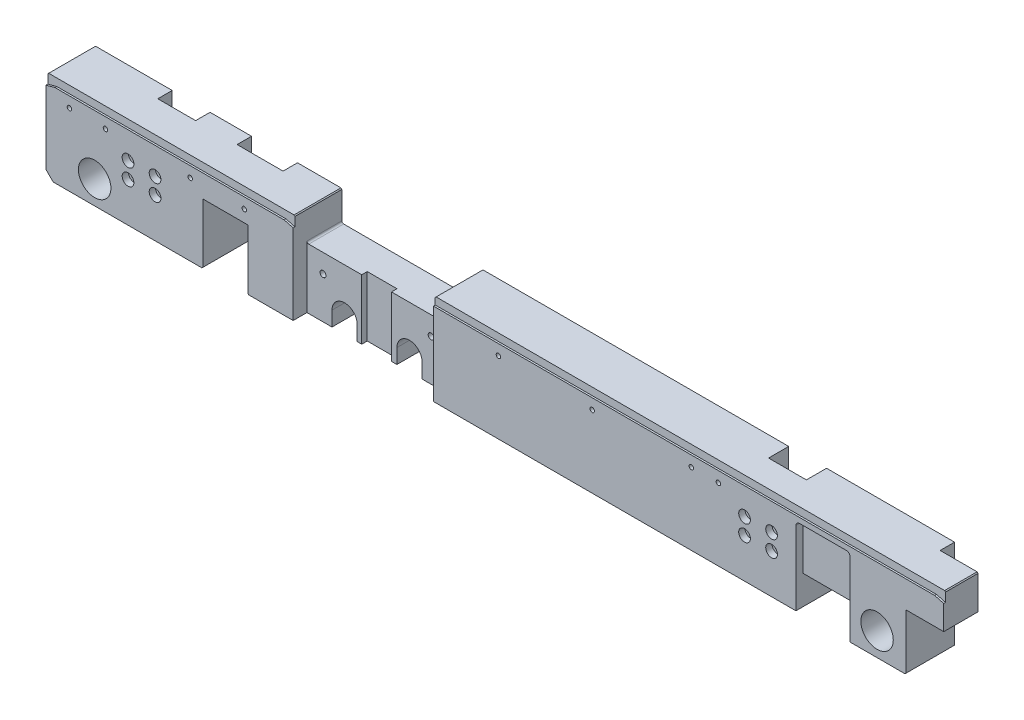
from build123d import *

# Parameters (mm, degrees)
SKETCH6_R             = 9
BOSS_EXTRUDE2_DEPTH   = 27
CHAMFER1_SIZE         = 4
CUT_EXTRUDE5_DEPTH    = 502.231483449
CHAMFER2_SIZE         = 0.5
CHAMFER3_SIZE         = 0.5
SKETCH8_W             = 30
SKETCH8_H             = 16
CUT_EXTRUDE6_DEPTH    = 27
SKETCH8_3_W           = 30
SKETCH8_3_H           = 27
CUT_EXTRUDE7_DEPTH    = 4
FILLET1_R             = 2
CUT_EXTRUDE8_DEPTH    = 1
SKETCH11_W            = 21
SKETCH11_H            = 28.648086621
CUT_EXTRUDE9_DEPTH    = 502.231483449
SKETCH12_W            = 21
SKETCH12_H            = 8
CUT_EXTRUDE10_DEPTH   = 500.693906307
SKETCH13_W            = 21
SKETCH13_H            = 30.21821637
CUT_EXTRUDE11_DEPTH   = 502.231483449
CUT_EXTRUDE12_DEPTH   = 500.847520656
SKETCH15_R            = 1.75
CUT_EXTRUDE13_DEPTH   = 502.231483449
SKETCH16_R            = 3.25
CUT_EXTRUDE14_DEPTH   = 3.5
FILLET2_R             = 1
M4_TAPPED_HOLE1_D     = 3.3
M4_TAPPED_HOLE1_DEPTH = 8
M4_TAPPED_HOLE1_TIP   = 0.991420021
M3_TAPPED_HOLE1_D     = 2.5
M3_TAPPED_HOLE1_DEPTH = 6
M3_TAPPED_HOLE1_TIP   = 0.751075774
M3_TAPPED_HOLE2_D     = 2.5
M3_TAPPED_HOLE2_DEPTH = 6
M3_TAPPED_HOLE2_TIP   = 0.751075774
M3_TAPPED_HOLE3_D     = 2.5
M3_TAPPED_HOLE3_DEPTH = 6
M3_TAPPED_HOLE3_TIP   = 0.751075774
M3_TAPPED_HOLE4_D     = 2.5
M3_TAPPED_HOLE4_DEPTH = 6
M3_TAPPED_HOLE4_TIP   = 0.751075774
M3_TAPPED_HOLE5_D     = 2.5
M3_TAPPED_HOLE5_DEPTH = 6
M3_TAPPED_HOLE5_TIP   = 0.751075774
SKETCH29_W            = 25.5
SKETCH29_H            = 8
CUT_EXTRUDE15_DEPTH   = 500.847520656


with BuildPart() as part:
    # Sketch6 → Boss-Extrude2 (new body)
    with BuildSketch(Plane.XY):
        Polygon((112, -50), (477, -50), (477, -19), (498, -19), (498, 0), (214.9, 0), (214.9, -16.61521445), (137.1, -16.61521445), (137.1, 0), (0, 0), (0, -50), (87, -50), (87, -16.61521445), (112, -16.61521445), align=None)
        with Locations((27, -37)):
            Circle(SKETCH6_R, mode=Mode.SUBTRACT)
        with Locations((461, -37)):
            Circle(SKETCH6_R, mode=Mode.SUBTRACT)
    extrude(amount=BOSS_EXTRUDE2_DEPTH)

    # Chamfer1
    chamfer1_edges = [part.edges().sort_by_distance(p)[0] for p in [
        (0, -50, 13.5),
    ]]
    chamfer(chamfer1_edges, length=CHAMFER1_SIZE)

    # Sketch7 → Cut-Extrude5 (cut, through all)
    with BuildSketch(Plane.XY.offset(27)):
        with BuildLine():
            Line((151, -41.853199992), (151, -50))
            Line((151, -50), (165, -50))
            Line((165, -50), (165, -41.853199992))
            ThreePointArc((165, -41.853199992), (158, -34.853199992), (151, -41.853199992))
        make_face()
        with BuildLine():
            Line((187, -50), (201, -50))
            Line((201, -50), (201, -41.853199992))
            ThreePointArc((201, -41.853199992), (194, -34.853199992), (187, -41.853199992))
            Line((187, -41.853199992), (187, -50))
        make_face()
    extrude(amount=-CUT_EXTRUDE5_DEPTH, mode=Mode.SUBTRACT)

    # Chamfer2
    chamfer2_edges = [part.edges().sort_by_distance(p)[0] for p in [
        (214.9, 0, 13.5),
        (137.1, 0, 13.5),
    ]]
    chamfer(chamfer2_edges, length=CHAMFER2_SIZE)

    # Chamfer3
    chamfer3_edges = [part.edges().sort_by_distance(p)[0] for p in [
        (112, -50, 13.5),
        (87, -50, 13.5),
        (0, 0, 13.5),
        (477, -50, 13.5),
        (498, 0, 13.5),
    ]]
    chamfer(chamfer3_edges, length=CHAMFER3_SIZE)

    # Sketch8 → Cut-Extrude6 (cut)
    with BuildSketch(Plane.XY.offset(27)):
        with Locations((431, -42)):
            Rectangle(SKETCH8_W, SKETCH8_H)
    extrude(amount=-CUT_EXTRUDE6_DEPTH, mode=Mode.SUBTRACT)

    # Sketch8_3 → Cut-Extrude7 (cut)
    with BuildSketch(Plane.XY.offset(27)):
        with Locations((431, -20.5)):
            Rectangle(SKETCH8_3_W, SKETCH8_3_H)
    extrude(amount=-CUT_EXTRUDE7_DEPTH, mode=Mode.SUBTRACT)

    # Fillet1
    fillet1_edges = [part.edges().sort_by_distance(p)[0] for p in [
        (446, -7, 25),
        (416, -7, 25),
    ]]
    fillet(fillet1_edges, radius=FILLET1_R)

    # Sketch10 → Cut-Extrude8 (cut)
    with BuildSketch(Plane.XY.offset(27)):
        Polygon((5, -4.129705764), (132.1, -4.129705764), (137.1, -5.469451726), (137.1, -4.129705764), (493, -4.129705764), (498, -5.469451726), (498.112682479, -4.129705764), (498.112682479, 0), (0, 0), (0, -4.129705764), (0, -5.469451726), align=None)
    extrude(amount=-CUT_EXTRUDE8_DEPTH, mode=Mode.SUBTRACT)

    # Sketch11 → Cut-Extrude9 (cut, through all)
    with BuildSketch(Plane.XZ.offset(50)):
        with Locations((53.5, -6.324043311)):
            Rectangle(SKETCH11_W, SKETCH11_H)
    extrude(amount=-CUT_EXTRUDE9_DEPTH, mode=Mode.SUBTRACT)

    # Sketch12 → Cut-Extrude10 (cut, through all)
    with BuildSketch(Plane.XZ.offset(19)):
        with Locations((487.5, 4)):
            Rectangle(SKETCH12_W, SKETCH12_H)
    extrude(amount=-CUT_EXTRUDE10_DEPTH, mode=Mode.SUBTRACT)

    # Sketch13 → Cut-Extrude11 (cut, through all)
    with BuildSketch(Plane.XZ.offset(50)):
        with Locations((395.5, -3.9138874)):
            Rectangle(SKETCH13_W, SKETCH13_H)
    extrude(amount=-CUT_EXTRUDE11_DEPTH, mode=Mode.SUBTRACT)

    # Sketch14 → Cut-Extrude12 (cut, through all)
    with BuildSketch(Plane(origin=(0, -16.61521445, 0), x_dir=(1, 0, 0), z_dir=(0, 1, 0))):
        Polygon((137.1, -27), (214.9, -27), (214.9, -19.35), (184, -19.35), (184, -16.3), (167.5, -16.3), (167.5, -19.35), (137.1, -19.35), align=None)
    extrude(amount=-CUT_EXTRUDE12_DEPTH, mode=Mode.SUBTRACT)

    # Sketch15 → Cut-Extrude13 (cut, through all)
    with BuildSketch(Plane.XY.offset(27)):
        with Locations((45.5, -19)):
            Circle(SKETCH15_R)
        with Locations((60.5, -19)):
            Circle(SKETCH15_R)
        with Locations((45.5, -28)):
            Circle(SKETCH15_R)
        with Locations((60.5, -28)):
            Circle(SKETCH15_R)
        with Locations((387.5, -19)):
            Circle(SKETCH15_R)
        with Locations((402.5, -19)):
            Circle(SKETCH15_R)
        with Locations((387.5, -28)):
            Circle(SKETCH15_R)
        with Locations((402.5, -28)):
            Circle(SKETCH15_R)
    extrude(amount=-CUT_EXTRUDE13_DEPTH, mode=Mode.SUBTRACT)

    # Sketch16 → Cut-Extrude14 (cut)
    with BuildSketch(Plane.XY.offset(27)):
        with Locations((45.5, -19)):
            Circle(SKETCH16_R)
        with Locations((60.5, -19)):
            Circle(SKETCH16_R)
        with Locations((60.5, -28)):
            Circle(SKETCH16_R)
        with Locations((45.5, -28)):
            Circle(SKETCH16_R)
        with Locations((387.5, -19)):
            Circle(SKETCH16_R)
        with Locations((402.5, -19)):
            Circle(SKETCH16_R)
        with Locations((402.5, -28)):
            Circle(SKETCH16_R)
        with Locations((387.5, -28)):
            Circle(SKETCH16_R)
    extrude(amount=-CUT_EXTRUDE14_DEPTH, mode=Mode.SUBTRACT)

    # Fillet2
    fillet2_edges = [part.edges().sort_by_distance(p)[0] for p in [
        (214.9, -16.61521445, 9.675),
        (137.1, -16.61521445, 9.675),
    ]]
    fillet(fillet2_edges, radius=FILLET2_R)

    # M4 Tapped Hole1
    with Locations(Plane.XY.offset(19.35)):
        with Locations((146, -27), (206, -27)):
            Hole(M4_TAPPED_HOLE1_D / 2, depth=M4_TAPPED_HOLE1_DEPTH)
            with Locations((0, 0, -(M4_TAPPED_HOLE1_DEPTH + M4_TAPPED_HOLE1_TIP / 2))):  # 118° drill point
                Cone(0, M4_TAPPED_HOLE1_D / 2, M4_TAPPED_HOLE1_TIP, mode=Mode.SUBTRACT)

    # M3 Tapped Hole1
    with Locations(Plane.XY.offset(27)):
        with Locations((13, -10), (33, -10), (80, -10), (110, -10), (251, -10), (303, -10), (373, -10), (358, -10)):
            Hole(M3_TAPPED_HOLE1_D / 2, depth=M3_TAPPED_HOLE1_DEPTH)
            with Locations((0, 0, -(M3_TAPPED_HOLE1_DEPTH + M3_TAPPED_HOLE1_TIP / 2))):  # 118° drill point
                Cone(0, M3_TAPPED_HOLE1_D / 2, M3_TAPPED_HOLE1_TIP, mode=Mode.SUBTRACT)

    # M3 Tapped Hole2
    with Locations(Plane(origin=(0, -19, 0), x_dir=(-1, 0, 0), z_dir=(0, -1, 0))):
        with Locations((-486, -12), (-494, -12)):
            Hole(M3_TAPPED_HOLE2_D / 2, depth=M3_TAPPED_HOLE2_DEPTH)
            with Locations((0, 0, -(M3_TAPPED_HOLE2_DEPTH + M3_TAPPED_HOLE2_TIP / 2))):  # 118° drill point
                Cone(0, M3_TAPPED_HOLE2_D / 2, M3_TAPPED_HOLE2_TIP, mode=Mode.SUBTRACT)

    # M3 Tapped Hole3
    with Locations(Plane(origin=(0, -34, 0), x_dir=(-1, 0, 0), z_dir=(0, -1, 0))):
        with Locations((-424.5, -15.24), (-437.5, -15.24)):
            Hole(M3_TAPPED_HOLE3_D / 2, depth=M3_TAPPED_HOLE3_DEPTH)
            with Locations((0, 0, -(M3_TAPPED_HOLE3_DEPTH + M3_TAPPED_HOLE3_TIP / 2))):  # 118° drill point
                Cone(0, M3_TAPPED_HOLE3_D / 2, M3_TAPPED_HOLE3_TIP, mode=Mode.SUBTRACT)

    # M3 Tapped Hole4
    with Locations(Plane(origin=(0, -50, 0), x_dir=(-1, 0, 0), z_dir=(0, -1, 0))):
        with Locations((-138.7, -12.9), (-146.7, -12.9)):
            Hole(M3_TAPPED_HOLE4_D / 2, depth=M3_TAPPED_HOLE4_DEPTH)
            with Locations((0, 0, -(M3_TAPPED_HOLE4_DEPTH + M3_TAPPED_HOLE4_TIP / 2))):  # 118° drill point
                Cone(0, M3_TAPPED_HOLE4_D / 2, M3_TAPPED_HOLE4_TIP, mode=Mode.SUBTRACT)

    # M3 Tapped Hole5
    with Locations(Plane(origin=(0, -16.61521445, 0), x_dir=(-1, 0, 0), z_dir=(0, -1, 0))):
        with Locations((-95.5, -12), (-103.5, -12)):
            Hole(M3_TAPPED_HOLE5_D / 2, depth=M3_TAPPED_HOLE5_DEPTH)
            with Locations((0, 0, -(M3_TAPPED_HOLE5_DEPTH + M3_TAPPED_HOLE5_TIP / 2))):  # 118° drill point
                Cone(0, M3_TAPPED_HOLE5_D / 2, M3_TAPPED_HOLE5_TIP, mode=Mode.SUBTRACT)

    # Sketch29 → Cut-Extrude15 (cut, through all)
    with BuildSketch(Plane.XZ.offset(16.61521445)):
        with Locations((99.75, 4)):
            Rectangle(SKETCH29_W, SKETCH29_H)
    extrude(amount=-CUT_EXTRUDE15_DEPTH, mode=Mode.SUBTRACT)


solid = part.part
